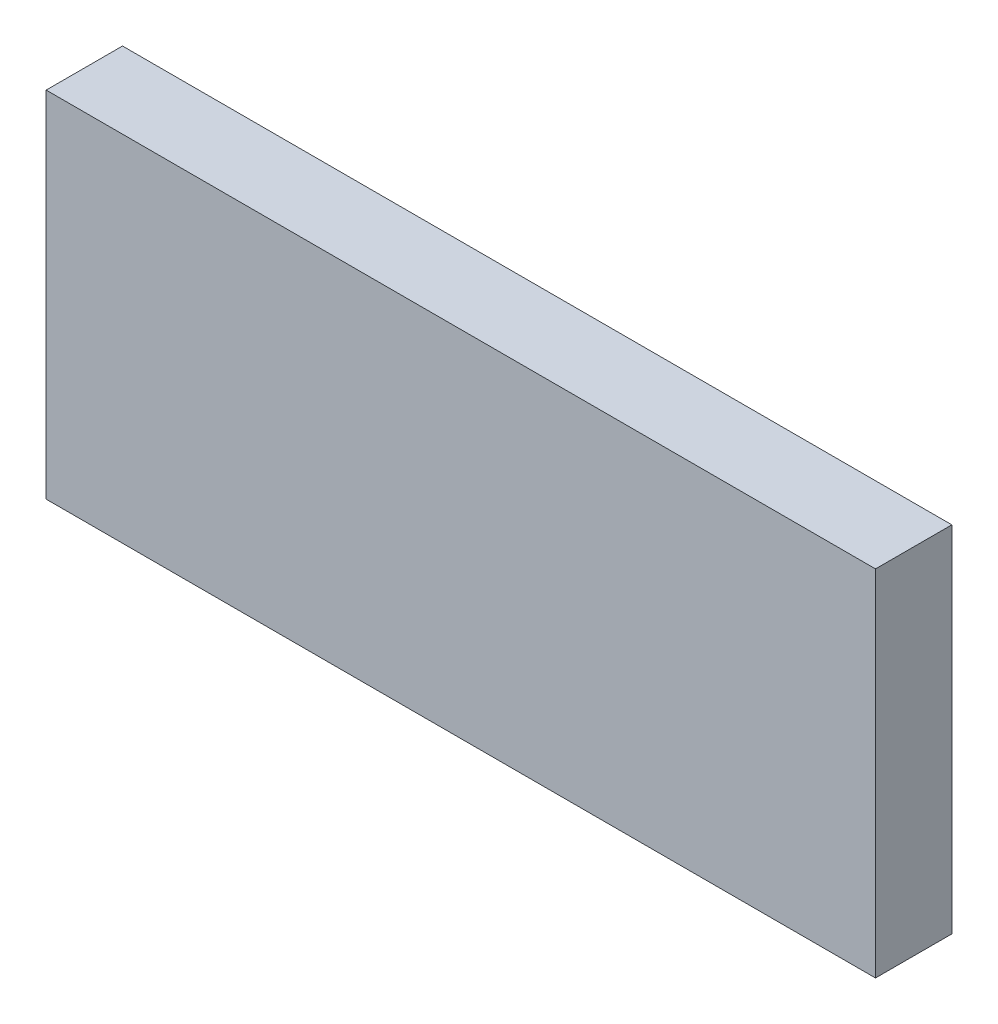
from build123d import *

# Parameters (mm, degrees)
ESQUISSE1_W        = 63.19
ESQUISSE1_H        = 27.85
BOSS_EXTRU_1_DEPTH = 6
ESQUISSE2_W        = 6
ESQUISSE2_H        = 27.85
BOSS_EXTRU_2_DEPTH = 2


with BuildPart() as part:
    # Esquisse1 → Boss.-Extru.1 (new body)
    with BuildSketch(Plane.XY):
        with Locations((-5.107040309, 7.485531136)):
            Rectangle(ESQUISSE1_W, ESQUISSE1_H)
    extrude(amount=BOSS_EXTRU_1_DEPTH)

    # Esquisse2 → Boss.-Extru.2 (add)
    with BuildSketch(Plane(origin=(26.487959691, 0, 0), x_dir=(0, 0, -1), z_dir=(1, 0, 0))):
        with Locations((-3, 7.485531136)):
            Rectangle(ESQUISSE2_W, ESQUISSE2_H)
    extrude(amount=BOSS_EXTRU_2_DEPTH)


solid = part.part
